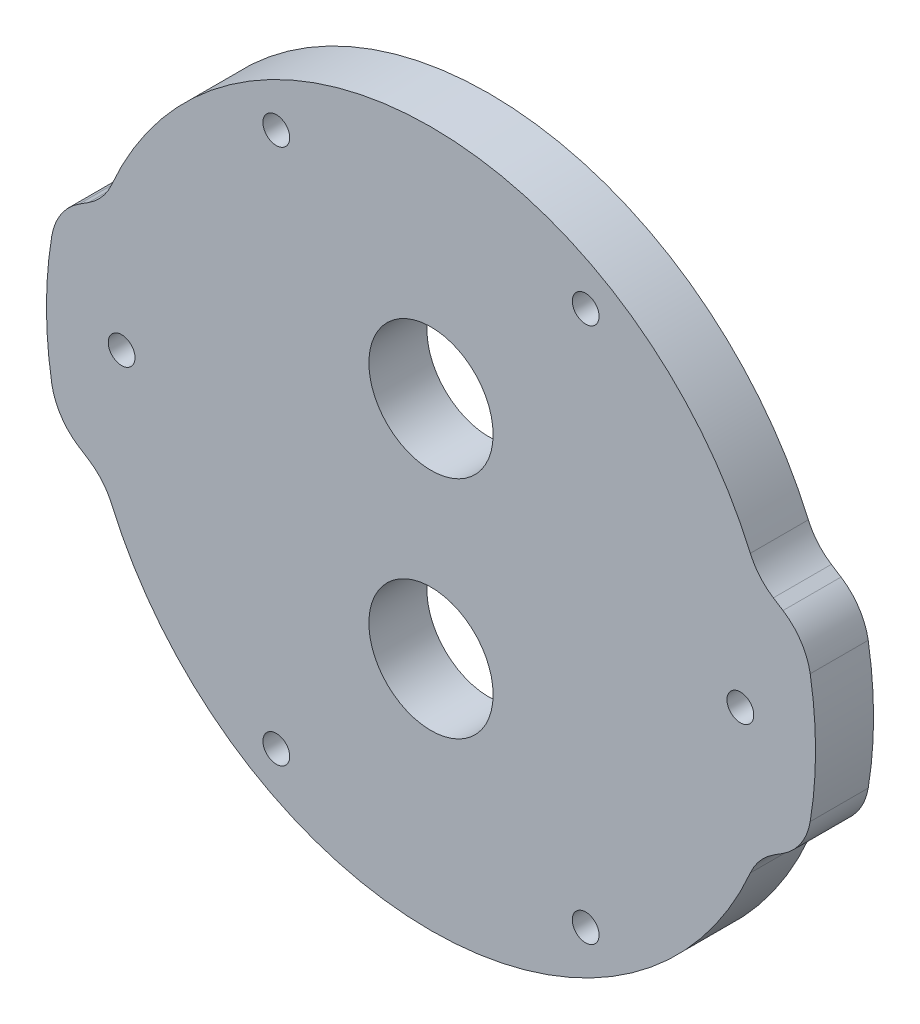
from build123d import *

# Parameters (mm, degrees)
SKETCH1_R           = 1.1
BOSS_EXTRUDE1_DEPTH = 4.7625
FILLET1_R           = 5
SKETCH3_R           = 5.1
CUT_EXTRUDE2_DEPTH  = 5.7625


with BuildPart() as part:
    # Sketch1 → Boss-Extrude1 (new body)
    with BuildSketch(Plane.XY):
        with BuildLine():
            Line((-30.671332299, 7.5), (-26.768089678, 10))
            ThreePointArc((-26.768089678, 10), (0, 28.575), (26.768089678, 10))
            Line((26.768089678, 10), (30.671332299, 7.5))
            ThreePointArc((30.671332299, 7.5), (31.575, 0), (30.671332299, -7.5))
            Line((30.671332299, -7.5), (26.768089678, -10))
            ThreePointArc((26.768089678, -10), (0, -28.575), (-26.768089678, -10))
            Line((-26.768089678, -10), (-30.671332299, -7.5))
            ThreePointArc((-30.671332299, -7.5), (-31.575, 0), (-30.671332299, 7.5))
        make_face()
        with Locations((-25.4, 0)):
            Circle(SKETCH1_R, mode=Mode.SUBTRACT)
        with Locations((-12.7, 21.997045256)):
            Circle(SKETCH1_R, mode=Mode.SUBTRACT)
        with Locations((12.7, 21.997045256)):
            Circle(SKETCH1_R, mode=Mode.SUBTRACT)
        with Locations((25.4, 0)):
            Circle(SKETCH1_R, mode=Mode.SUBTRACT)
        with Locations((12.7, -21.997045256)):
            Circle(SKETCH1_R, mode=Mode.SUBTRACT)
        with Locations((-12.7, -21.997045256)):
            Circle(SKETCH1_R, mode=Mode.SUBTRACT)
    extrude(amount=BOSS_EXTRUDE1_DEPTH)

    # Fillet1
    fillet1_edges = [part.edges().sort_by_distance(p)[0] for p in [
        (30.671332299, -7.5, 2.38125),
        (26.768089678, -10, 2.38125),
        (-26.768089678, -10, 2.38125),
        (-30.671332299, -7.5, 2.38125),
        (-30.671332299, 7.5, 2.38125),
        (-26.768089678, 10, 2.38125),
        (26.768089678, 10, 2.38125),
        (30.671332299, 7.5, 2.38125),
    ]]
    fillet(fillet1_edges, radius=FILLET1_R)

    # Sketch3 → Cut-Extrude2 (cut, through all)
    with BuildSketch(Plane.XY.offset(4.7625)):
        with Locations((0, -9.25)):
            Circle(SKETCH3_R)
        with Locations((0, 9.25)):
            Circle(SKETCH3_R)
    extrude(amount=-CUT_EXTRUDE2_DEPTH, mode=Mode.SUBTRACT)


solid = part.part
